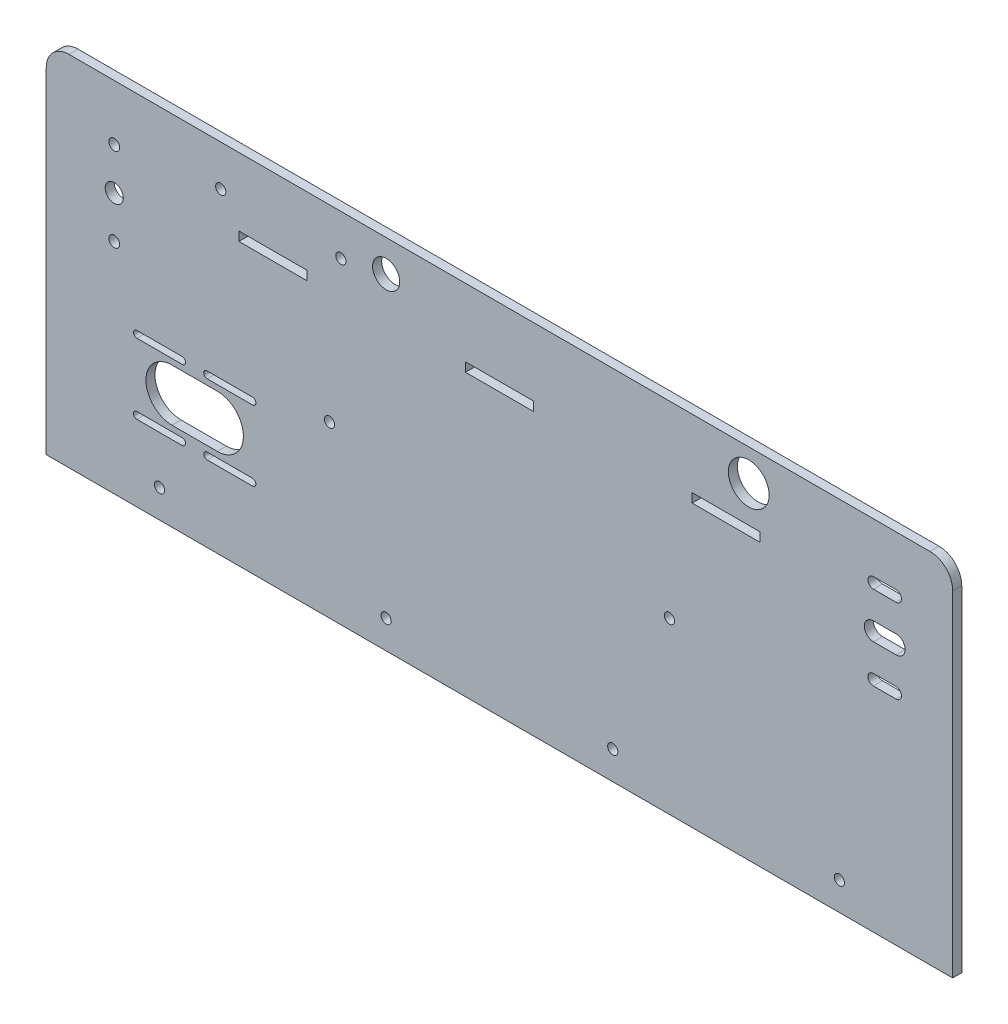
from build123d import *

# Parameters (mm, degrees)
ESBO_O1_R                = 2.4
ESBO_O1_W                = 30
ESBO_O1_H                = 4
RESSALTO_EXTRUS_O1_DEPTH = 4
ESBO_O3_R                = 4
CORTE_EXTRUS_O1_DEPTH    = 6
FURO_COM_FOLGA_DE_M41_D  = 4.5
RESSALTO_EXTRUS_O2_DEPTH = 4
ESBO_O8_R                = 6
ESBO_O8_R_2              = 9
CORTE_EXTRUS_O4_DEPTH    = 5


with BuildPart() as part:
    # Esboço1 → Ressalto-extrusão1 (new body)
    with BuildSketch(Plane.XY):
        with BuildLine():
            Line((120, 130), (120, 140))
            ThreePointArc((120, 140), (122.928932188, 147.071067812), (130, 150))
            Line((130, 150), (50, 150))
            ThreePointArc((50, 150), (57.071067812, 147.071067812), (60, 140))
            Line((60, 140), (60, 130))
            Line((60, 130), (120, 130))
        make_face()
        with BuildLine():
            Line((0, 140), (0, 0))
            Line((0, 0), (400, 0))
            Line((400, 0), (400, 140))
            ThreePointArc((400, 140), (397.071067812, 147.071067812), (390, 150))
            Line((390, 150), (319, 150))
            Line((319, 150), (301, 150))
            Line((301, 150), (130, 150))
            ThreePointArc((130, 150), (122.928932188, 147.071067812), (120, 140))
            Line((120, 140), (120, 130))
            Line((120, 130), (60, 130))
            Line((60, 130), (60, 140))
            ThreePointArc((60, 140), (57.071067812, 147.071067812), (50, 150))
            Line((50, 150), (10, 150))
            ThreePointArc((10, 150), (2.928932188, 147.071067812), (0, 140))
        make_face()
        with Locations((30, 96.5)):
            Circle(ESBO_O1_R, mode=Mode.SUBTRACT)
        with Locations((30, 133.5)):
            Circle(ESBO_O1_R, mode=Mode.SUBTRACT)
        with Locations((100, 126)):
            Rectangle(ESBO_O1_W, ESBO_O1_H, mode=Mode.SUBTRACT)
        with BuildLine():
            ThreePointArc((365, 94.1), (362.6, 96.5), (365, 98.9))
            Line((365, 98.9), (375, 98.9))
            ThreePointArc((375, 98.9), (377.4, 96.5), (375, 94.1))
            Line((375, 94.1), (365, 94.1))
        make_face(mode=Mode.SUBTRACT)
        with Locations((200, 126)):
            Rectangle(ESBO_O1_W, ESBO_O1_H, mode=Mode.SUBTRACT)
        with Locations((300, 126)):
            Rectangle(ESBO_O1_W, ESBO_O1_H, mode=Mode.SUBTRACT)
        with BuildLine():
            ThreePointArc((365, 131.1), (362.6, 133.5), (365, 135.9))
            Line((365, 135.9), (375, 135.9))
            ThreePointArc((375, 135.9), (377.4, 133.5), (375, 131.1))
            Line((375, 131.1), (365, 131.1))
        make_face(mode=Mode.SUBTRACT)
    extrude(amount=RESSALTO_EXTRUS_O1_DEPTH)

    # Esboço3 → Corte-extrusão1 (cut)
    with BuildSketch(Plane.XY.offset(4)):
        with Locations((30, 115)):
            Circle(ESBO_O3_R)
        with BuildLine():
            Line((365, 119), (375, 119))
            ThreePointArc((375, 119), (379, 115), (375, 111))
            Line((375, 111), (365, 111))
            ThreePointArc((365, 111), (361, 115), (365, 119))
        make_face()
        with BuildLine():
            Line((40, 67.5), (60, 67.5))
            ThreePointArc((60, 67.5), (61.5, 66), (60, 64.5))
            Line((60, 64.5), (40, 64.5))
            ThreePointArc((40, 64.5), (38.5, 66), (40, 67.5))
        make_face()
        with BuildLine():
            Line((71, 36.5), (91, 36.5))
            ThreePointArc((91, 36.5), (92.5, 35), (91, 33.5))
            Line((91, 33.5), (71, 33.5))
            ThreePointArc((71, 33.5), (69.5, 35), (71, 36.5))
        make_face()
        with BuildLine():
            Line((71, 67.5), (91, 67.5))
            ThreePointArc((91, 67.5), (92.5, 66), (91, 64.5))
            Line((91, 64.5), (71, 64.5))
            ThreePointArc((71, 64.5), (69.5, 66), (71, 67.5))
        make_face()
        with BuildLine():
            Line((40, 36.5), (60, 36.5))
            ThreePointArc((60, 36.5), (61.5, 35), (60, 33.5))
            Line((60, 33.5), (40, 33.5))
            ThreePointArc((40, 33.5), (38.5, 35), (40, 36.5))
        make_face()
        with BuildLine():
            Line((55.5, 62), (75.5, 62))
            ThreePointArc((75.5, 62), (87, 50.5), (75.5, 39))
            Line((75.5, 39), (55.5, 39))
            ThreePointArc((55.5, 39), (44, 50.5), (55.5, 62))
        make_face()
    extrude(amount=-CORTE_EXTRUS_O1_DEPTH, mode=Mode.SUBTRACT)

    # Furo com folga de M41 (through all)
    with Locations(Plane(origin=(50, 12.5, 4), x_dir=(1, 0, 0), z_dir=(0, 0, 1))):
        with Locations((0, 0), (100, 0), (200, 0), (300, 0), (225, 62.5), (75, 62.5), (27, 127.5), (80, 127.5)):
            Hole(FURO_COM_FOLGA_DE_M41_D / 2)

    # Esboço5 → Ressalto-extrusão2 (add)
    with BuildSketch(Plane.XY.offset(4)):
        with BuildLine():
            Line((0, 140), (0, 148))
            ThreePointArc((0, 148), (2.928932188, 155.071067812), (10, 158))
            Line((10, 158), (390, 158))
            ThreePointArc((390, 158), (397.071067812, 155.071067812), (400, 148))
            Line((400, 148), (400, 140))
            ThreePointArc((400, 140), (397.071067812, 147.071067812), (390, 150))
            Line((390, 150), (10, 150))
            ThreePointArc((10, 150), (2.928932188, 147.071067812), (0, 140))
        make_face()
    extrude(amount=-RESSALTO_EXTRUS_O2_DEPTH)

    # Esboço8 → Corte-extrusão4 (cut, through all)
    with BuildSketch(Plane.XY):
        with Locations((150, 144)):
            Circle(ESBO_O8_R)
        with Locations((310, 144)):
            Circle(ESBO_O8_R_2)
    extrude(amount=CORTE_EXTRUS_O4_DEPTH, mode=Mode.SUBTRACT)


solid = part.part
